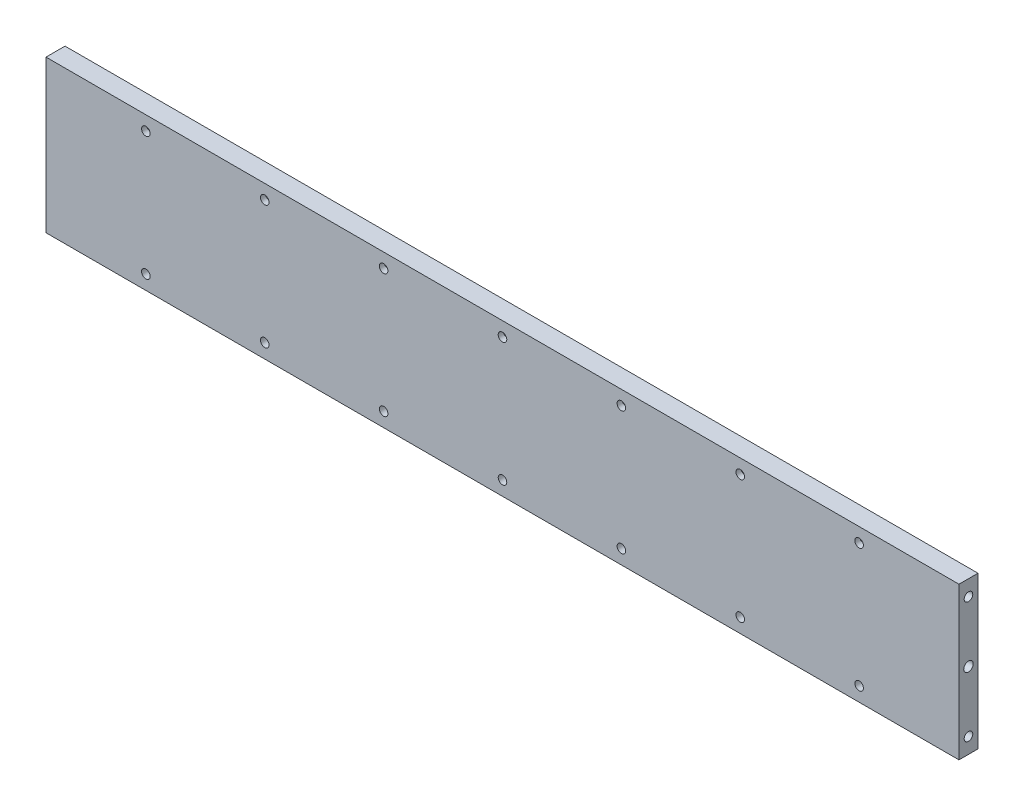
from build123d import *

# Parameters (mm, degrees)
SKETCH1_W           = 384
SKETCH1_H           = 64
SKETCH1_R           = 1.8
BOSS_EXTRUDE1_DEPTH = 8
CUT_EXTRUDE1_REACH  = 386
SKETCH2_R           = 1.8
SKETCH2_R_2         = 2


with BuildPart() as part:
    # Sketch1 → Boss-Extrude1 (new body)
    with BuildSketch(Plane.XY):
        Rectangle(SKETCH1_W, SKETCH1_H)
        with Locations((0, 26)):
            Circle(SKETCH1_R, mode=Mode.SUBTRACT)
        with Locations((50, 26)):
            Circle(SKETCH1_R, mode=Mode.SUBTRACT)
        with Locations((100, 26)):
            Circle(SKETCH1_R, mode=Mode.SUBTRACT)
        with Locations((150, 26)):
            Circle(SKETCH1_R, mode=Mode.SUBTRACT)
        with Locations((-50, 26)):
            Circle(SKETCH1_R, mode=Mode.SUBTRACT)
        with Locations((-100, 26)):
            Circle(SKETCH1_R, mode=Mode.SUBTRACT)
        with Locations((-150, 26)):
            Circle(SKETCH1_R, mode=Mode.SUBTRACT)
        with Locations((-150, -26)):
            Circle(SKETCH1_R, mode=Mode.SUBTRACT)
        with Locations((-100, -26)):
            Circle(SKETCH1_R, mode=Mode.SUBTRACT)
        with Locations((-50, -26)):
            Circle(SKETCH1_R, mode=Mode.SUBTRACT)
        with Locations((150, -26)):
            Circle(SKETCH1_R, mode=Mode.SUBTRACT)
        with Locations((100, -26)):
            Circle(SKETCH1_R, mode=Mode.SUBTRACT)
        with Locations((50, -26)):
            Circle(SKETCH1_R, mode=Mode.SUBTRACT)
        with Locations((0, -26)):
            Circle(SKETCH1_R, mode=Mode.SUBTRACT)
    extrude(amount=BOSS_EXTRUDE1_DEPTH)

    # Sketch2 → Cut-Extrude1 (cut, up to next)
    with BuildSketch(Plane.ZY.offset(192), mode=Mode.PRIVATE) as cut_extrude1_sk1:
        with Locations((4, 25.445)):
            Circle(SKETCH2_R)
    cut_extrude1_tool1 = extrude(cut_extrude1_sk1.sketch, amount=-CUT_EXTRUDE1_REACH, mode=Mode.PRIVATE) & part.part
    add(cut_extrude1_tool1.solids().sort_by_distance((-192, 25.445, 4))[0], mode=Mode.SUBTRACT)
    # Sketch2 → Cut-Extrude1 (cut, up to next)
    with BuildSketch(Plane.ZY.offset(192), mode=Mode.PRIVATE) as cut_extrude1_sk2:
        with Locations((4, -25.445)):
            Circle(SKETCH2_R)
    cut_extrude1_tool2 = extrude(cut_extrude1_sk2.sketch, amount=-CUT_EXTRUDE1_REACH, mode=Mode.PRIVATE) & part.part
    add(cut_extrude1_tool2.solids().sort_by_distance((-192, -25.445, 4))[0], mode=Mode.SUBTRACT)
    # Sketch2 → Cut-Extrude1 (cut, up to next)
    with BuildSketch(Plane.ZY.offset(192), mode=Mode.PRIVATE) as cut_extrude1_sk3:
        with Locations((4, 0)):
            Circle(SKETCH2_R_2)
    cut_extrude1_tool3 = extrude(cut_extrude1_sk3.sketch, amount=-CUT_EXTRUDE1_REACH, mode=Mode.PRIVATE) & part.part
    add(cut_extrude1_tool3.solids().sort_by_distance((-192, 0, 4))[0], mode=Mode.SUBTRACT)


solid = part.part
